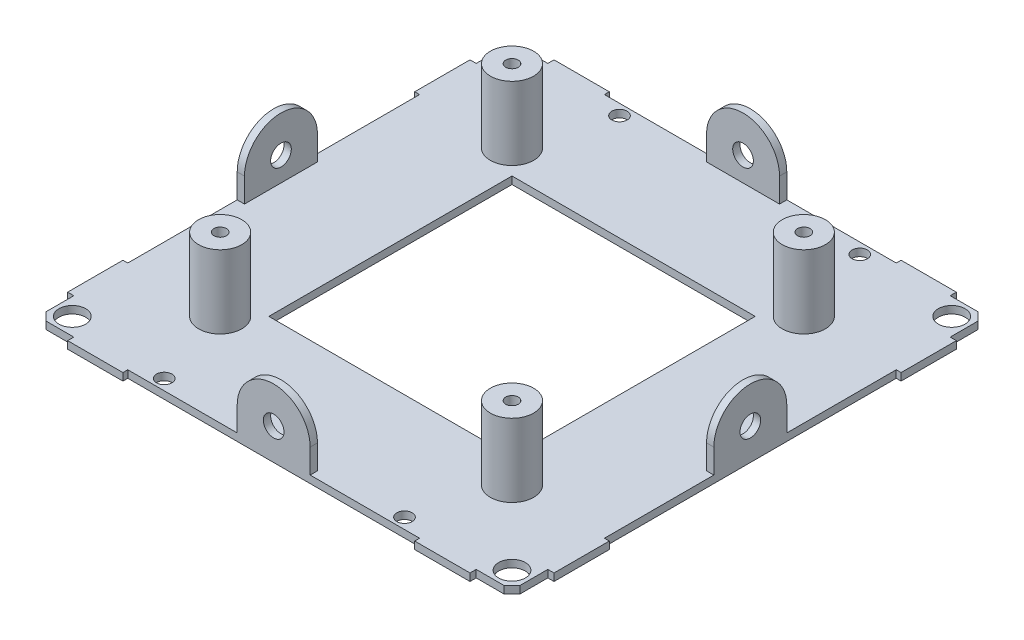
from build123d import *

# Parameters (mm, degrees)
SKETCH1_R                 = 2.7503
SKETCH1_R_2               = 1.575
SKETCH1_W                 = 50
SKETCH1_H                 = 50
BOSS_EXTRUDE1_DEPTH       = 1.524
SKETCH2_W                 = 15
SKETCH2_H                 = 2.5
SKETCH2_W_2               = 2.5
SKETCH2_H_2               = 15
BOSS_EXTRUDE2_DEPTH       = 12.476
SKETCH3_R                 = 2.125
CUT_EXTRUDE1_DEPTH        = 1
CUT_EXTRUDE1_DEPTH_BACK   = 101
SKETCH4_R                 = 2.125
CUT_EXTRUDE2_DEPTH        = 1
CUT_EXTRUDE2_DEPTH_BACK   = 101
SKETCH5_W                 = 60
SKETCH5_H                 = 1
SKETCH5_W_2               = 1
SKETCH5_H_2               = 60
CUT_EXTRUDE3_DEPTH        = 1
CUT_EXTRUDE3_DEPTH_BACK   = 15
SKETCH6_R                 = 4.445
BOSS_EXTRUDE3_DEPTH       = 15
F_5_40_TAPPED_HOLE1_D     = 2.5781
F_5_40_TAPPED_HOLE1_DEPTH = 15
F_5_40_TAPPED_HOLE1_TIP   = 0.774539381


with BuildPart() as part:
    # Sketch1 → Boss-Extrude1 (new body)
    with BuildSketch(Plane(origin=(0, 0, 0), x_dir=(1, 0, 0), z_dir=(0, 1, 0))):
        Polygon((41.364, 50), (-41.364, 50), (-41.364, 48.73), (-47.079, 48.73), (-48.73, 47.079), (-48.73, 41.364), (-50, 41.364), (-50, -41.364), (-48.73, -41.364), (-48.73, -47.079), (-47.079, -48.73), (-41.364, -48.73), (-41.364, -50), (41.364, -50), (41.364, -48.73), (47.079, -48.73), (48.73, -47.079), (48.73, -41.364), (50, -41.364), (50, 41.364), (48.73, 41.364), (48.73, 47.079), (47.079, 48.73), (41.364, 48.73), align=None)
        with Locations((-45.2, -45.2)):
            Circle(SKETCH1_R, mode=Mode.SUBTRACT)
        with Locations((-24.7, -46.8)):
            Circle(SKETCH1_R_2, mode=Mode.SUBTRACT)
        with Locations((24.7, -46.8)):
            Circle(SKETCH1_R_2, mode=Mode.SUBTRACT)
        with Locations((45.2, -45.2)):
            Circle(SKETCH1_R, mode=Mode.SUBTRACT)
        Rectangle(SKETCH1_W, SKETCH1_H, mode=Mode.SUBTRACT)
        with Locations((-45.2, 45.2)):
            Circle(SKETCH1_R, mode=Mode.SUBTRACT)
        with Locations((-24.7, 46.8)):
            Circle(SKETCH1_R_2, mode=Mode.SUBTRACT)
        with BuildLine():
            ThreePointArc((26.275, 46.8), (24.7, 45.225), (23.125, 46.8))
            ThreePointArc((23.125, 46.8), (24.7, 48.375), (26.275, 46.8))
        make_face(mode=Mode.SUBTRACT)
        with Locations((45.2, 45.2)):
            Circle(SKETCH1_R, mode=Mode.SUBTRACT)
    extrude(amount=BOSS_EXTRUDE1_DEPTH)

    # Sketch2 → Boss-Extrude2 (add)
    with BuildSketch(Plane(origin=(0, 1.524, 0), x_dir=(1, 0, 0), z_dir=(0, 1, 0))):
        with Locations((0, 48.75)):
            Rectangle(SKETCH2_W, SKETCH2_H)
        with Locations((48.75, 0)):
            Rectangle(SKETCH2_W_2, SKETCH2_H_2)
        with Locations((0, -48.75)):
            Rectangle(SKETCH2_W, SKETCH2_H)
        with Locations((-48.75, 0)):
            Rectangle(SKETCH2_W_2, SKETCH2_H_2)
    extrude(amount=BOSS_EXTRUDE2_DEPTH)

    # Sketch3 → Cut-Extrude1 (cut, two sides)
    with BuildSketch(Plane.XY.offset(50)) as cut_extrude1_sk:
        with BuildLine():
            ThreePointArc((0, 14), (5.303300859, 11.803300859), (7.5, 6.5))
            Line((7.5, 6.5), (7.5, 14))
            Line((7.5, 14), (0, 14))
        make_face()
        with BuildLine():
            ThreePointArc((-7.5, 6.5), (-5.303300859, 11.803300859), (0, 14))
            Line((0, 14), (-7.5, 14))
            Line((-7.5, 14), (-7.5, 6.5))
        make_face()
        with Locations((0, 6.5)):
            Circle(SKETCH3_R)
    extrude(amount=CUT_EXTRUDE1_DEPTH, mode=Mode.SUBTRACT)
    extrude(cut_extrude1_sk.sketch, amount=-CUT_EXTRUDE1_DEPTH_BACK, mode=Mode.SUBTRACT)

    # Sketch4 → Cut-Extrude2 (cut, two sides)
    with BuildSketch(Plane.ZY.offset(50)) as cut_extrude2_sk:
        with Locations((0, 6.5)):
            Circle(SKETCH4_R)
        with BuildLine():
            ThreePointArc((0, 14), (5.303300859, 11.803300859), (7.5, 6.5))
            Line((7.5, 6.5), (7.5, 14))
            Line((7.5, 14), (0, 14))
        make_face()
        with BuildLine():
            ThreePointArc((-7.5, 6.5), (-5.303300859, 11.803300859), (0, 14))
            Line((0, 14), (-7.5, 14))
            Line((-7.5, 14), (-7.5, 6.5))
        make_face()
    extrude(amount=CUT_EXTRUDE2_DEPTH, mode=Mode.SUBTRACT)
    extrude(cut_extrude2_sk.sketch, amount=-CUT_EXTRUDE2_DEPTH_BACK, mode=Mode.SUBTRACT)

    # Sketch5 → Cut-Extrude3 (cut, two sides)
    with BuildSketch(Plane.XZ) as cut_extrude3_sk:
        with Locations((0, -49.5)):
            Rectangle(SKETCH5_W, SKETCH5_H)
        with Locations((-49.5, 0)):
            Rectangle(SKETCH5_W_2, SKETCH5_H_2)
        with Locations((0, 49.5)):
            Rectangle(SKETCH5_W, SKETCH5_H)
        with Locations((49.5, 0)):
            Rectangle(SKETCH5_W_2, SKETCH5_H_2)
    extrude(amount=CUT_EXTRUDE3_DEPTH, mode=Mode.SUBTRACT)
    extrude(cut_extrude3_sk.sketch, amount=-CUT_EXTRUDE3_DEPTH_BACK, mode=Mode.SUBTRACT)

    # Sketch6 → Boss-Extrude3 (add)
    with BuildSketch(Plane(origin=(0, 1.524, 0), x_dir=(1, 0, 0), z_dir=(0, 1, 0))):
        with Locations((30, 30)):
            Circle(SKETCH6_R)
        with Locations((30, -30)):
            Circle(SKETCH6_R)
        with Locations((-30, -30)):
            Circle(SKETCH6_R)
        with Locations((-30, 30)):
            Circle(SKETCH6_R)
    extrude(amount=BOSS_EXTRUDE3_DEPTH)

    # #5-40 Tapped Hole1
    with Locations(Plane(origin=(0, 16.524, 0), x_dir=(1, 0, 0), z_dir=(0, 1, 0))):
        with Locations((-17.222965343, 16.834933913), (-30, 30), (-30, -30), (30, -30), (30, 30)):
            Hole(F_5_40_TAPPED_HOLE1_D / 2, depth=F_5_40_TAPPED_HOLE1_DEPTH)
            with Locations((0, 0, -(F_5_40_TAPPED_HOLE1_DEPTH + F_5_40_TAPPED_HOLE1_TIP / 2))):  # 118° drill point
                Cone(0, F_5_40_TAPPED_HOLE1_D / 2, F_5_40_TAPPED_HOLE1_TIP, mode=Mode.SUBTRACT)


solid = part.part
